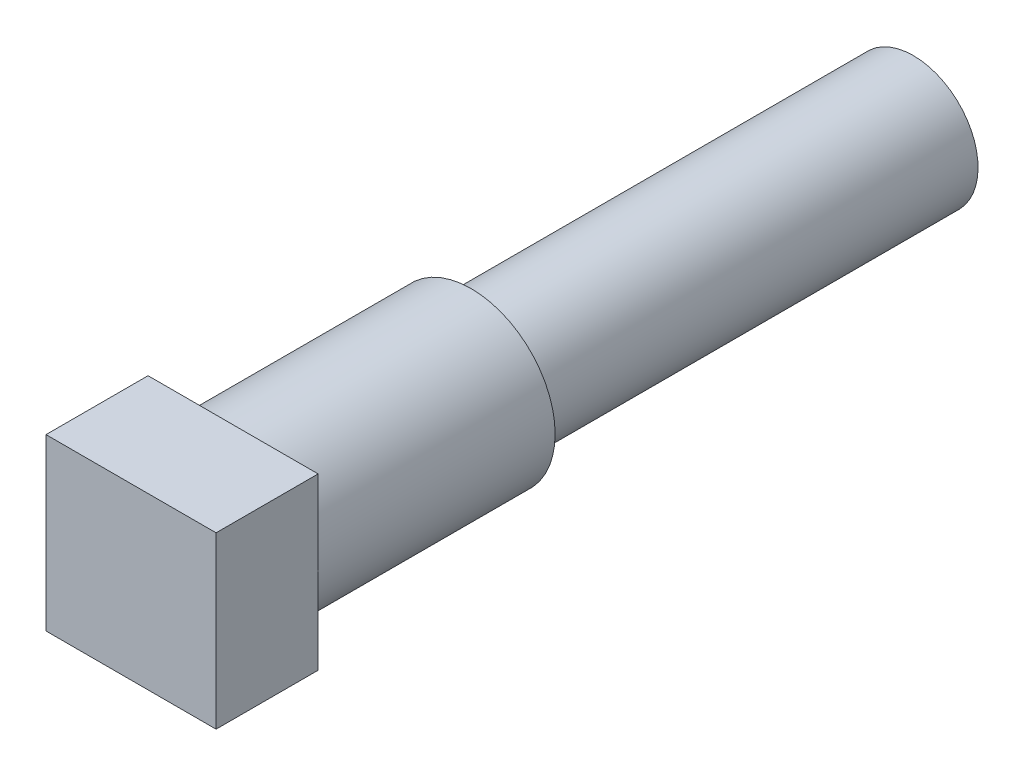
from build123d import *

# Parameters (mm, degrees)
SKETCH6_R           = 3.687499751
CUT_EXTRUDE3_DEPTH  = 29.1338
SKETCH7_R           = 2.413
BOSS_EXTRUDE1_DEPTH = 16.51
SKETCH9_R           = 4.699
CUT_EXTRUDE4_DEPTH  = 6.35
SKETCH10_W          = 6.35
SKETCH10_H          = 6.35
BOSS_EXTRUDE3_DEPTH = 3.81


with BuildPart() as part:
    # Sketch1 → Revolve1 (revolve)
    with BuildSketch(Plane(origin=(0, 0, 0), x_dir=(0, 0, -1), z_dir=(1, 0, 0))):
        Polygon((4.892085627, 0), (44.3738, 0), (44.3738, 2.159), (43.409235, 3.123565), (25.3238, 3.123565), (18.9738, 3.133725), (6.4516, 3.133725), (6.2738, 3.133725), (6.2738, 3.311525), (6.2738, 4.445), (6.2738, 4.699), (6.0198, 4.699), (0.635, 4.699), (0, 4.699), (0, 4.064), (0, 3.19405), (0, 0), align=None)
    revolve(axis=Axis((0, 0, -4.892085627), (0, 0, -1)))

    # Sketch6 → Cut-Extrude3 (cut)
    with BuildSketch(Plane(origin=(0, 0, -44.3738), x_dir=(-1, 0, 0), z_dir=(0, 0, -1))):
        Circle(SKETCH6_R)
    extrude(amount=-CUT_EXTRUDE3_DEPTH, mode=Mode.SUBTRACT)

    # Sketch7 → Boss-Extrude1 (add)
    with BuildSketch(Plane(origin=(0, 0, -15.24), x_dir=(-1, 0, 0), z_dir=(0, 0, -1))):
        Circle(SKETCH7_R)
    extrude(amount=BOSS_EXTRUDE1_DEPTH)

    # Sketch9 → Cut-Extrude4 (cut)
    with BuildSketch(Plane.XY):
        Circle(SKETCH9_R)
    extrude(amount=-CUT_EXTRUDE4_DEPTH, mode=Mode.SUBTRACT)

    # Sketch10 → Boss-Extrude3 (add)
    with BuildSketch(Plane.XY.offset(-6.35)):
        Rectangle(SKETCH10_W, SKETCH10_H)
    extrude(amount=BOSS_EXTRUDE3_DEPTH)


solid = part.part
